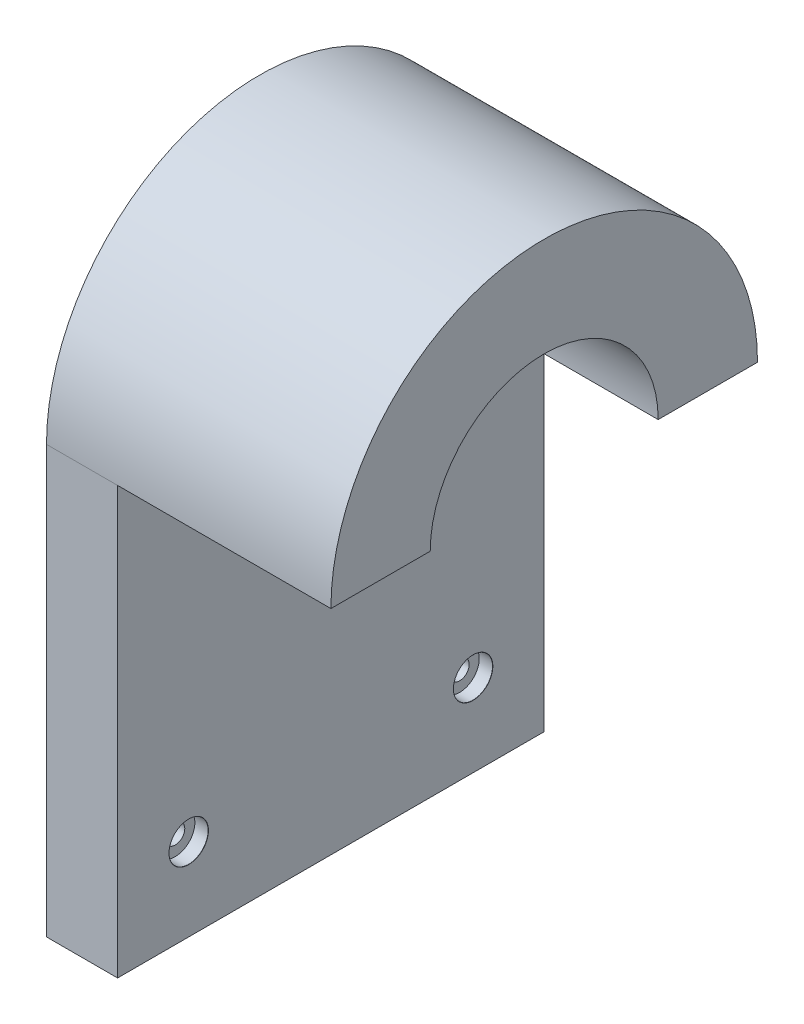
from build123d import *

# Parameters (mm, degrees)
BOSS_EXTRUDE3_DEPTH                           = 12.7
BOSS_EXTRUDE4_DEPTH                           = 38.1
CBORE_FOR_M3_PAN_HEAD_MACHINE_SCREW1_AT_COUNT = 2
CBORE_FOR_M3_PAN_HEAD_MACHINE_SCREW1_AT_PITCH = 66.51875294
CBORE_FOR_M3_PAN_HEAD_MACHINE_SCREW1_2_COUNT  = 2
CBORE_FOR_M3_PAN_HEAD_MACHINE_SCREW1_2_PITCH  = 66.51875294


with BuildPart() as part:
    # Sketch1 → Boss-Extrude3 (new body)
    with BuildSketch(Plane(origin=(0, 0, 0), x_dir=(0, 0, -1), z_dir=(1, 0, 0))):
        with BuildLine():
            Line((38.1, -76.2), (38.1, 0))
            ThreePointArc((38.1, 0), (0, 38.1), (-38.1, 0))
            Line((-38.1, 0), (-38.1, -76.2))
            Line((-38.1, -76.2), (38.1, -76.2))
        make_face()
    extrude(amount=BOSS_EXTRUDE3_DEPTH)

    # Sketch5 → Boss-Extrude4 (add)
    with BuildSketch(Plane(origin=(12.7, 0, 0), x_dir=(0, 0, -1), z_dir=(1, 0, 0))):
        with BuildLine():
            ThreePointArc((-20.358389677, 0), (0, 20.358389677), (20.358389677, 0))
            Line((20.358389677, 0), (38.1, 0))
            ThreePointArc((38.1, 0), (0, 38.1), (-38.1, 0))
            Line((-38.1, 0), (-20.358389677, 0))
        make_face()
    extrude(amount=BOSS_EXTRUDE4_DEPTH)

    # Sketch8 → CBORE for M3 Pan Head Machine Screw1 (revolve, cut)
    with BuildSketch(Plane(origin=(12.7, 0, 0), x_dir=(0, 0, -1), z_dir=(0, 1, 0))):
        Polygon((0, 0), (0, 12.7), (1.7, 12.7), (1.7, 2.4), (3.5, 2.4), (3.5, 0.025), (3.525, 0), align=None)
    cbore_for_m3_pan_head_machine_screw1 = revolve(axis=Axis((19.05, 0, 0), (-1, 0, 0)), mode=Mode.SUBTRACT)

    # CBORE for M3 Pan Head Machine Screw1 at: CBORE for M3 Pan Head Machine Screw1 ×2
    with Locations(*[Vector(0, -0.924225465, 0.381847207) * (i * CBORE_FOR_M3_PAN_HEAD_MACHINE_SCREW1_AT_PITCH) for i in range(1, CBORE_FOR_M3_PAN_HEAD_MACHINE_SCREW1_AT_COUNT)]):
        add(cbore_for_m3_pan_head_machine_screw1, mode=Mode.SUBTRACT)

    # CBORE for M3 Pan Head Machine Screw1 2: CBORE for M3 Pan Head Machine Screw1 ×2
    with Locations(*[Vector(0, -0.924225465, -0.381847207) * (i * CBORE_FOR_M3_PAN_HEAD_MACHINE_SCREW1_2_PITCH) for i in range(1, CBORE_FOR_M3_PAN_HEAD_MACHINE_SCREW1_2_COUNT)]):
        add(cbore_for_m3_pan_head_machine_screw1, mode=Mode.SUBTRACT)


solid = part.part
